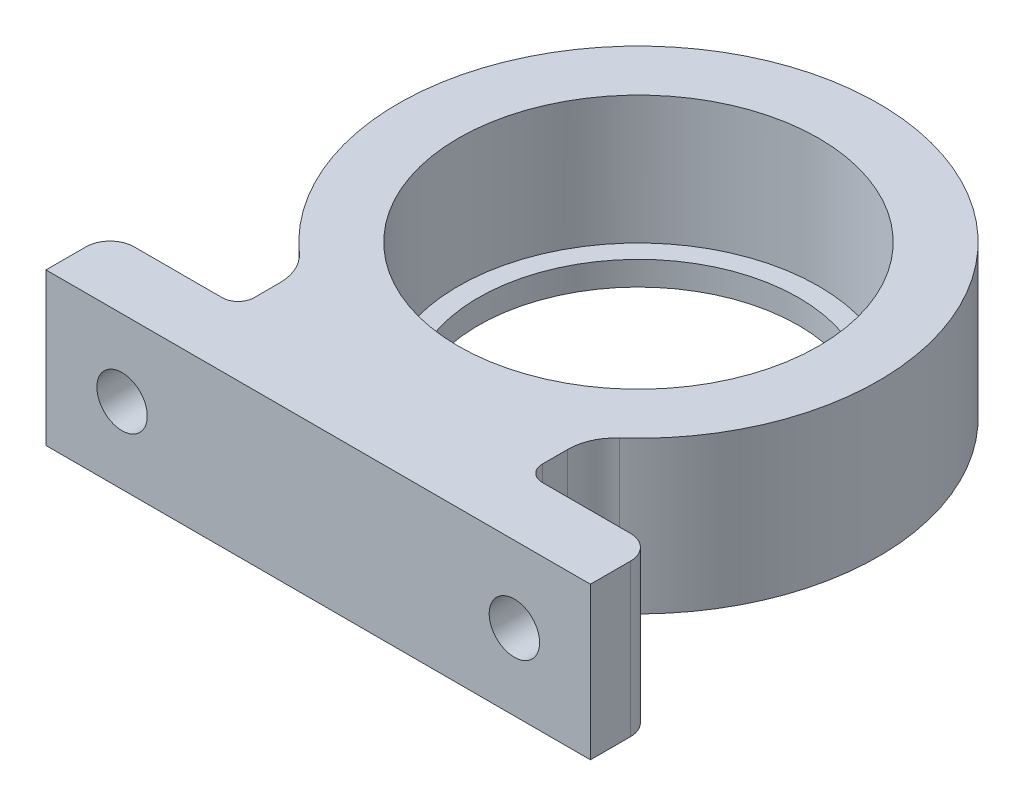
from build123d import *
from OCP.BRepFilletAPI import BRepFilletAPI_MakeFillet

# Parameters (mm, degrees)
SKETCH3_R           = 11.25
BOSS_EXTRUDE5_DEPTH = 9.5
SKETCH11_R          = 11.25
SKETCH11_R_2        = 10
BOSS_EXTRUDE6_DEPTH = 1.5
SKETCH12_R          = 1.575
CUT_EXTRUDE3_DEPTH  = 37.609425016
SKETCH13_R          = 1.575
CUT_EXTRUDE4_DEPTH  = 37.609425016
FILLET1_R1          = 3
FILLET1_R2          = 1


with BuildPart() as part:
    # Sketch3 → Boss-Extrude5 (new body)
    with BuildSketch(Plane(origin=(0, 0, 0), x_dir=(1, 0, 0), z_dir=(0, 1, 0))):
        with BuildLine():
            Line((-9, 4.422205102), (-15.5, 4.422205102))
            ThreePointArc((-15.5, 4.422205102), (-16.560660172, 3.982865274), (-17, 2.922205102))
            Line((-17, 2.922205102), (-17, 0.422205102))
            Line((-17, 0.422205102), (17, 0.422205102))
            Line((17, 0.422205102), (17, 2.922205102))
            ThreePointArc((17, 2.922205102), (16.560660172, 3.982865274), (15.5, 4.422205102))
            Line((15.5, 4.422205102), (9, 4.422205102))
            Line((9, 4.422205102), (9, 8.422205102))
            ThreePointArc((9, 8.422205102), (0, 35.422205102), (-9, 8.422205102))
            Line((-9, 8.422205102), (-9, 4.422205102))
        make_face()
        with Locations((0, 20.422205102)):
            Circle(SKETCH3_R, mode=Mode.SUBTRACT)
    extrude(amount=BOSS_EXTRUDE5_DEPTH)

    # Sketch11 → Boss-Extrude6 (add)
    with BuildSketch(Plane.XZ):
        with Locations((0, -20.422205102)):
            Circle(SKETCH11_R)
        with Locations((0, -20.422205102)):
            Circle(SKETCH11_R_2, mode=Mode.SUBTRACT)
    extrude(amount=-BOSS_EXTRUDE6_DEPTH)

    # Sketch12 → Cut-Extrude3 (cut, through all)
    with BuildSketch(Plane(origin=(0, 0, -4.422205102), x_dir=(-1, 0, 0), z_dir=(0, 0, -1))):
        with Locations((12.25, 4.75)):
            Circle(SKETCH12_R)
    extrude(amount=-CUT_EXTRUDE3_DEPTH, mode=Mode.SUBTRACT)

    # Sketch13 → Cut-Extrude4 (cut, through all)
    with BuildSketch(Plane(origin=(0, 0, -4.422205102), x_dir=(-1, 0, 0), z_dir=(0, 0, -1))):
        with Locations((-12.25, 4.75)):
            Circle(SKETCH13_R)
    extrude(amount=-CUT_EXTRUDE4_DEPTH, mode=Mode.SUBTRACT)

    # Fillet1: one fillet with a radius per group of edges: ONE call of the kernel's fillet builder (fillet() takes one radius for all edges)
    fillet1_edges_1 = [part.edges().sort_by_distance(p)[0] for p in [
        (-9, 4.75, -8.422205102),
        (9, 4.75, -8.422205102),
    ]]
    fillet1_edges_2 = [part.edges().sort_by_distance(p)[0] for p in [
        (-9, 4.75, -4.422205102),
        (9, 4.75, -4.422205102),
    ]]
    fillet1 = BRepFilletAPI_MakeFillet(part.part.solid().wrapped)
    for e in fillet1_edges_1:
        fillet1.Add(FILLET1_R1, e.wrapped)
    for e in fillet1_edges_2:
        fillet1.Add(FILLET1_R2, e.wrapped)
    add(Compound.cast(fillet1.Shape()), mode=Mode.REPLACE)


solid = part.part
